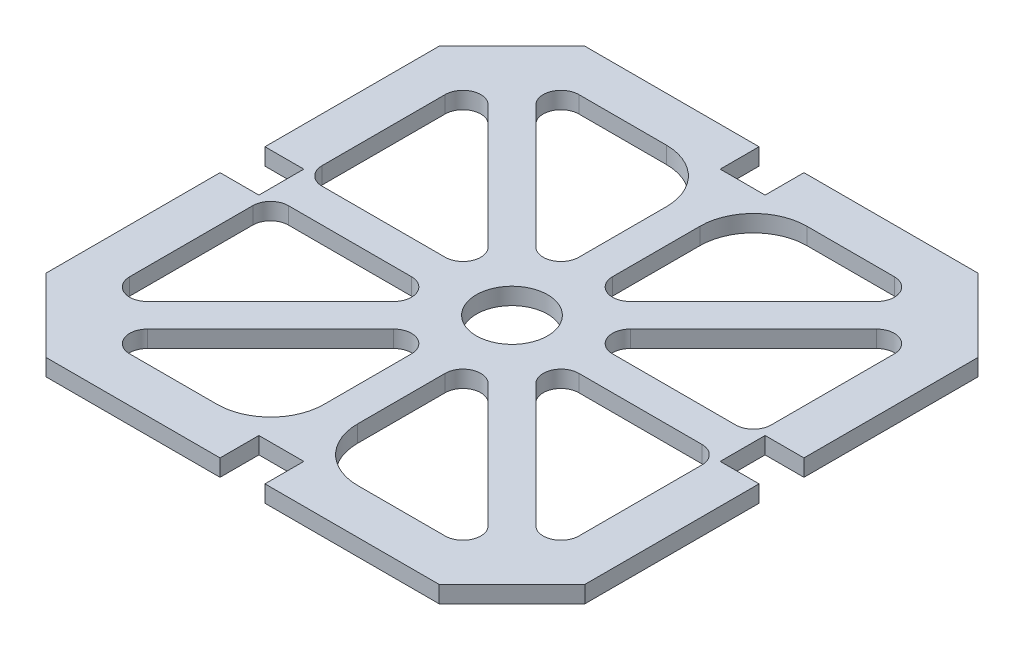
from build123d import *

# Parameters (mm, degrees)
SKETCH1_R           = 6.35
BOSS_EXTRUDE1_DEPTH = 3


with BuildPart() as part:
    # Sketch1 → Boss-Extrude1 (new body)
    with BuildSketch(Plane(origin=(0, 0, 0), x_dir=(1, 0, 0), z_dir=(0, 1, 0))):
        Polygon((48, -4), (41.080632081, -4), (41.080632081, 4), (48, 4), (48, 35), (35, 48), (4, 48), (4, 41.080632081), (-4, 41.080632081), (-4, 48), (-35, 48), (-48, 35), (-48, 4), (-41.08063208, 4), (-41.08063208, -4), (-48, -4), (-48, -35), (-35, -48), (-4, -48), (-4, -41.080632081), (4, -41.080632081), (4, -48), (35, -48), (48, -35), align=None)
        Circle(SKETCH1_R, mode=Mode.SUBTRACT)
        with BuildLine():
            Line((-30.337295283, 34.57993597), (-8.42006403, 12.662704717))
            ThreePointArc((-8.42006403, 12.662704717), (-4.959980102, 11.974451232), (-3, 14.907768748))
            Line((-3, 14.907768748), (-3, 30.475))
            ThreePointArc((-3, 30.475), (-5.789807909, 37.210192091), (-12.525, 40))
            Line((-12.525, 40), (-28.092231252, 40))
            ThreePointArc((-28.092231252, 40), (-31.025548768, 38.040019898), (-30.337295283, 34.57993597))
        make_face(mode=Mode.SUBTRACT)
        with BuildLine():
            Line((3, 14.907768748), (3, 30.475))
            ThreePointArc((3, 30.475), (5.789807909, 37.210192091), (12.525, 40))
            Line((12.525, 40), (28.092231252, 40))
            ThreePointArc((28.092231252, 40), (31.025548768, 38.040019898), (30.337295283, 34.57993597))
            Line((30.337295283, 34.57993597), (8.42006403, 12.662704717))
            ThreePointArc((8.42006403, 12.662704717), (4.959980102, 11.974451232), (3, 14.907768748))
        make_face(mode=Mode.SUBTRACT)
        with BuildLine():
            Line((12.662704717, 8.42006403), (34.57993597, 30.337295283))
            ThreePointArc((34.57993597, 30.337295283), (38.040019898, 31.025548768), (40, 28.092231252))
            Line((40, 28.092231252), (40, 6.175))
            ThreePointArc((40, 6.175), (39.07006403, 3.92993597), (36.825, 3))
            Line((36.825, 3), (14.907768748, 3))
            ThreePointArc((14.907768748, 3), (11.974451232, 4.959980102), (12.662704717, 8.42006403))
        make_face(mode=Mode.SUBTRACT)
        with BuildLine():
            Line((40, -6.175), (40, -28.092231252))
            ThreePointArc((40, -28.092231252), (38.040019898, -31.025548768), (34.57993597, -30.337295283))
            Line((34.57993597, -30.337295283), (12.662704717, -8.42006403))
            ThreePointArc((12.662704717, -8.42006403), (11.974451232, -4.959980102), (14.907768747, -3))
            Line((14.907768747, -3), (36.825, -3))
            ThreePointArc((36.825, -3), (39.07006403, -3.92993597), (40, -6.175))
        make_face(mode=Mode.SUBTRACT)
        with BuildLine():
            Line((30.337295283, -34.57993597), (8.42006403, -12.662704717))
            ThreePointArc((8.42006403, -12.662704717), (4.959980102, -11.974451232), (3, -14.907768748))
            Line((3, -14.907768748), (3, -30.475))
            ThreePointArc((3, -30.475), (5.789807909, -37.210192091), (12.525, -40))
            Line((12.525, -40), (28.092231252, -40))
            ThreePointArc((28.092231252, -40), (31.025548768, -38.040019898), (30.337295283, -34.57993597))
        make_face(mode=Mode.SUBTRACT)
        with BuildLine():
            Line((-3, -14.907768748), (-3, -30.475))
            ThreePointArc((-3, -30.475), (-5.789807909, -37.210192091), (-12.525, -40))
            Line((-12.525, -40), (-28.092231252, -40))
            ThreePointArc((-28.092231252, -40), (-31.025548768, -38.040019898), (-30.337295283, -34.57993597))
            Line((-30.337295283, -34.57993597), (-8.42006403, -12.662704717))
            ThreePointArc((-8.42006403, -12.662704717), (-4.959980102, -11.974451232), (-3, -14.907768748))
        make_face(mode=Mode.SUBTRACT)
        with BuildLine():
            Line((-34.57993597, -30.337295283), (-12.662704717, -8.42006403))
            ThreePointArc((-12.662704717, -8.42006403), (-11.974451232, -4.959980102), (-14.907768747, -3))
            Line((-14.907768747, -3), (-36.825, -3))
            ThreePointArc((-36.825, -3), (-39.07006403, -3.92993597), (-40, -6.175))
            Line((-40, -6.175), (-40, -28.092231252))
            ThreePointArc((-40, -28.092231252), (-38.040019898, -31.025548768), (-34.57993597, -30.337295283))
        make_face(mode=Mode.SUBTRACT)
        with BuildLine():
            Line((-36.825, 3), (-14.907768748, 3))
            ThreePointArc((-14.907768748, 3), (-11.974451232, 4.959980102), (-12.662704717, 8.42006403))
            Line((-12.662704717, 8.42006403), (-34.57993597, 30.337295283))
            ThreePointArc((-34.57993597, 30.337295283), (-38.040019898, 31.025548768), (-40, 28.092231252))
            Line((-40, 28.092231252), (-40, 6.175))
            ThreePointArc((-40, 6.175), (-39.07006403, 3.92993597), (-36.825, 3))
        make_face(mode=Mode.SUBTRACT)
    extrude(amount=BOSS_EXTRUDE1_DEPTH)


solid = part.part
